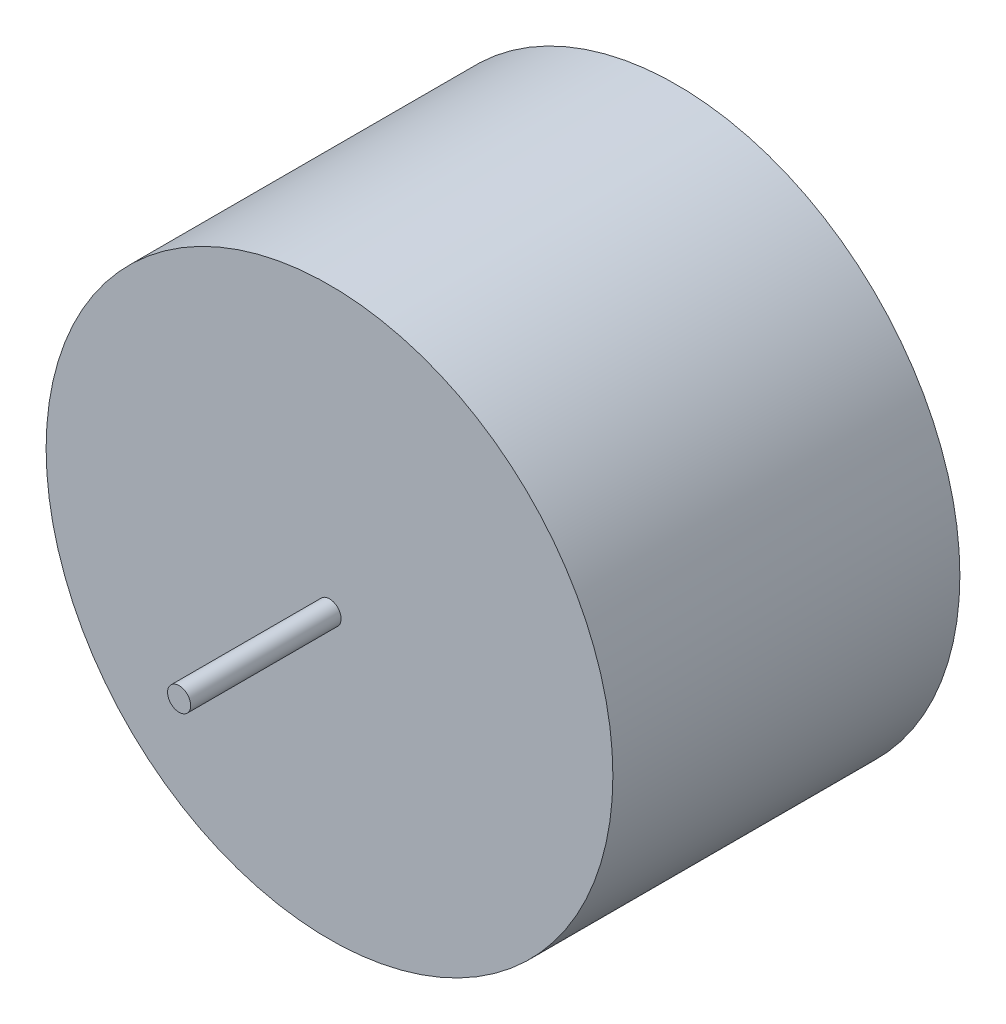
from build123d import *

# Parameters (mm, degrees)
CROQUIS1_R              = 85.75
SALIENTE_EXTRUIR1_DEPTH = 105
CROQUIS2_R              = 21
SALIENTE_EXTRUIR2_DEPTH = 10.5
CROQUIS3_R              = 3.5
SALIENTE_EXTRUIR4_DEPTH = 150.5


with BuildPart() as part:
    # Croquis1 → Saliente-Extruir1 (new body)
    with BuildSketch(Plane.XY):
        Circle(CROQUIS1_R)
    extrude(amount=SALIENTE_EXTRUIR1_DEPTH)

    # Croquis2 → Saliente-Extruir2 (add)
    with BuildSketch(Plane.XY):
        Circle(CROQUIS2_R)
    extrude(amount=-SALIENTE_EXTRUIR2_DEPTH)

    # Croquis3 → Saliente-Extruir4 (add)
    with BuildSketch(Plane(origin=(0, 0, 0), x_dir=(-1, 0, 0), z_dir=(0, 0, -1))):
        Circle(CROQUIS3_R)
    extrude(amount=-SALIENTE_EXTRUIR4_DEPTH)


solid = part.part
